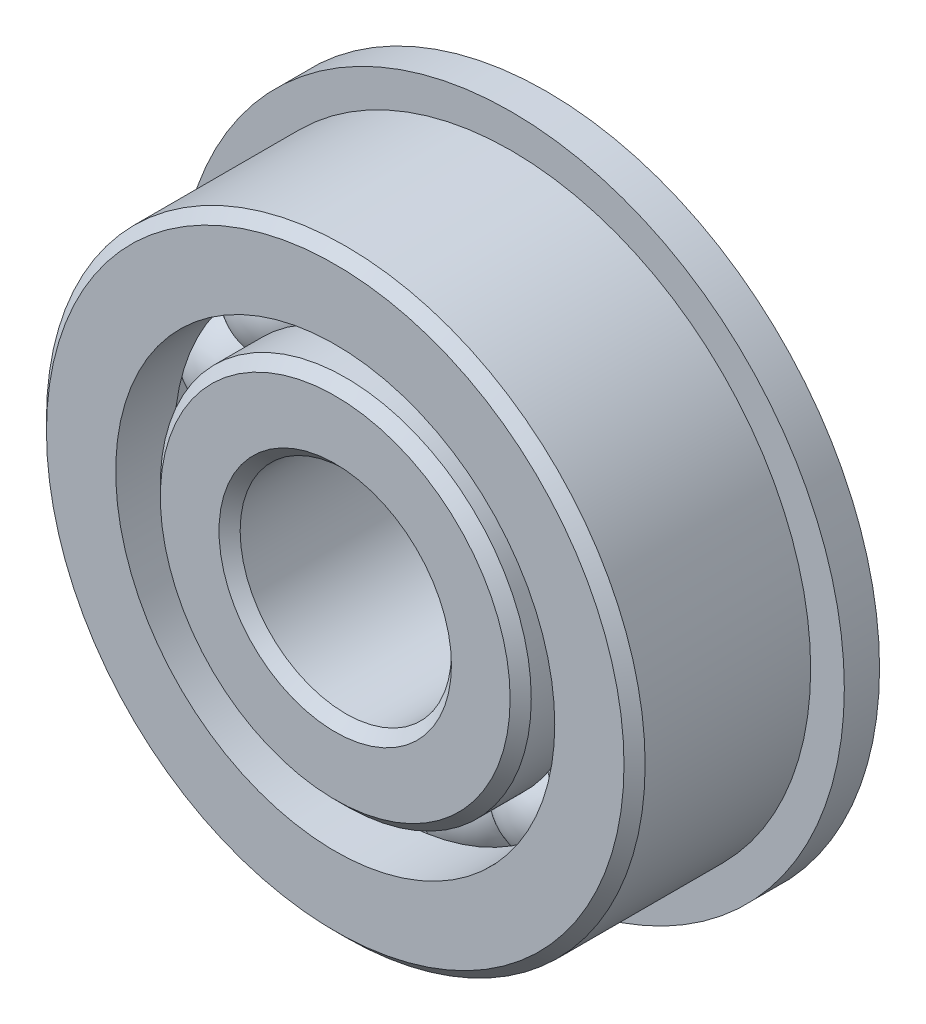
from build123d import *

# Parameters (mm, degrees)
CIRPATTERN1_COUNT = 15
SKETCH6_W         = 1.5875
SKETCH6_H         = 5.115692582


with BuildPart() as part:
    # Sketch1 → Revolve1 (revolve)
    with BuildSketch(Plane(origin=(0, 0, 0), x_dir=(0, 0, -1), z_dir=(1, 0, 0))):
        with BuildLine():
            Line((4.28625, 13.49375), (-4.28625, 13.49375))
            Line((-4.28625, 13.49375), (-4.7625, 13.0175))
            Line((-4.7625, 13.0175), (-4.7625, 9.895707418))
            Line((-4.7625, 9.895707418), (-2.116666667, 9.895707418))
            ThreePointArc((-2.116666667, 9.895707418), (0, 11.379671257), (2.116666667, 9.895707418))
            Line((2.116666667, 9.895707418), (4.7625, 9.895707418))
            Line((4.7625, 9.895707418), (4.7625, 13.0175))
            Line((4.7625, 13.0175), (4.28625, 13.49375))
        make_face()
    revolve(axis=Axis((0, 0, 4.7625), (0, 0, -1)))

    # Sketch6 → Revolve6 (revolve)
    with BuildSketch(Plane(origin=(0, 0, 0), x_dir=(0, 0, -1), z_dir=(1, 0, 0))):
        with Locations((3.96875, 12.453553709)):
            Rectangle(SKETCH6_W, SKETCH6_H)
    revolve(axis=Axis((0, 0, -4.7625), (0, 0, 1)))


with BuildPart() as body_2:
    # Sketch3 → Revolve3 (revolve)
    with BuildSketch(Plane(origin=(0, 0, 0), x_dir=(0, 0, -1), z_dir=(1, 0, 0))):
        with BuildLine():
            Line((-4.7625, 5.23875), (-4.7625, 7.884292582))
            Line((-4.7625, 7.884292582), (-4.28625, 8.360542582))
            Line((-4.28625, 8.360542582), (-2.116666667, 8.360542582))
            ThreePointArc((-2.116666667, 8.360542582), (0, 6.876578743), (2.116666667, 8.360542582))
            Line((2.116666667, 8.360542582), (5.87375, 8.360542582))
            Line((5.87375, 8.360542582), (6.35, 7.884292582))
            Line((6.35, 7.884292582), (6.35, 5.23875))
            Line((6.35, 5.23875), (5.87375, 4.7625))
            Line((5.87375, 4.7625), (-4.28625, 4.7625))
            Line((-4.28625, 4.7625), (-4.7625, 5.23875))
        make_face()
    revolve(axis=Axis((0, 0, 4.7625), (0, 0, -1)))


with BuildPart() as body_3:
    # Sketch4 → Revolve4 (revolve)
    with BuildSketch(Plane(origin=(0, 0, 0), x_dir=(0, 0, -1), z_dir=(1, 0, 0))):
        with BuildLine():
            Line((-2.251546257, 9.128125), (2.251546257, 9.128125))
            ThreePointArc((2.251546257, 9.128125), (0, 11.379671257), (-2.251546257, 9.128125))
        make_face()
    revolve(axis=Axis((0, 9.128125, 2.251546257), (0, 0, -1)))


with BuildPart() as cirpattern1_1:
    # CirPattern1: pattern copy
    add(body_3.part.rotate(Axis((0, 0, -4.7625), (0, 0, 1)), 1 * 360 / CIRPATTERN1_COUNT))


with BuildPart() as cirpattern1_2:
    # CirPattern1: pattern copy
    add(body_3.part.rotate(Axis((0, 0, -4.7625), (0, 0, 1)), 2 * 360 / CIRPATTERN1_COUNT))


with BuildPart() as cirpattern1_3:
    # CirPattern1: pattern copy
    add(body_3.part.rotate(Axis((0, 0, -4.7625), (0, 0, 1)), 3 * 360 / CIRPATTERN1_COUNT))


with BuildPart() as cirpattern1_4:
    # CirPattern1: pattern copy
    add(body_3.part.rotate(Axis((0, 0, -4.7625), (0, 0, 1)), 4 * 360 / CIRPATTERN1_COUNT))


with BuildPart() as cirpattern1_5:
    # CirPattern1: pattern copy
    add(body_3.part.rotate(Axis((0, 0, -4.7625), (0, 0, 1)), 5 * 360 / CIRPATTERN1_COUNT))


with BuildPart() as cirpattern1_6:
    # CirPattern1: pattern copy
    add(body_3.part.rotate(Axis((0, 0, -4.7625), (0, 0, 1)), 6 * 360 / CIRPATTERN1_COUNT))


with BuildPart() as cirpattern1_7:
    # CirPattern1: pattern copy
    add(body_3.part.rotate(Axis((0, 0, -4.7625), (0, 0, 1)), 7 * 360 / CIRPATTERN1_COUNT))


with BuildPart() as cirpattern1_8:
    # CirPattern1: pattern copy
    add(body_3.part.rotate(Axis((0, 0, -4.7625), (0, 0, 1)), 8 * 360 / CIRPATTERN1_COUNT))


with BuildPart() as cirpattern1_9:
    # CirPattern1: pattern copy
    add(body_3.part.rotate(Axis((0, 0, -4.7625), (0, 0, 1)), 9 * 360 / CIRPATTERN1_COUNT))


with BuildPart() as cirpattern1_10:
    # CirPattern1: pattern copy
    add(body_3.part.rotate(Axis((0, 0, -4.7625), (0, 0, 1)), 10 * 360 / CIRPATTERN1_COUNT))


with BuildPart() as cirpattern1_11:
    # CirPattern1: pattern copy
    add(body_3.part.rotate(Axis((0, 0, -4.7625), (0, 0, 1)), 11 * 360 / CIRPATTERN1_COUNT))


with BuildPart() as cirpattern1_12:
    # CirPattern1: pattern copy
    add(body_3.part.rotate(Axis((0, 0, -4.7625), (0, 0, 1)), 12 * 360 / CIRPATTERN1_COUNT))


with BuildPart() as cirpattern1_13:
    # CirPattern1: pattern copy
    add(body_3.part.rotate(Axis((0, 0, -4.7625), (0, 0, 1)), 13 * 360 / CIRPATTERN1_COUNT))


with BuildPart() as cirpattern1_14:
    # CirPattern1: pattern copy
    add(body_3.part.rotate(Axis((0, 0, -4.7625), (0, 0, 1)), 14 * 360 / CIRPATTERN1_COUNT))


solid = Compound([part.part, body_2.part, body_3.part, cirpattern1_1.part, cirpattern1_2.part, cirpattern1_3.part, cirpattern1_4.part, cirpattern1_5.part, cirpattern1_6.part, cirpattern1_7.part, cirpattern1_8.part, cirpattern1_9.part, cirpattern1_10.part, cirpattern1_11.part, cirpattern1_12.part, cirpattern1_13.part, cirpattern1_14.part])
